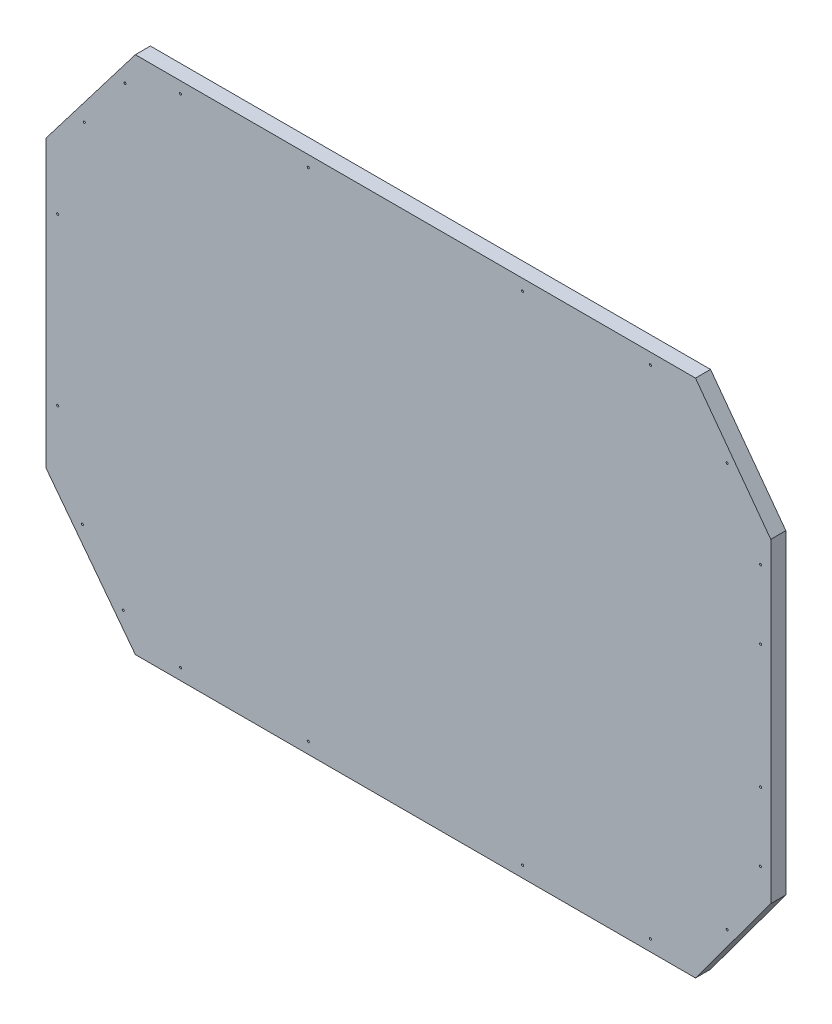
from build123d import *

# Parameters (mm, degrees)
BOSS_EXTRUDE2_DEPTH                               = 20
CSK_FOR_3_FLAT_HEAD_MACHINE_SCREW_100_D           = 2.794
CSK_FOR_3_FLAT_HEAD_MACHINE_SCREW_100_DEPTH       = 20
CSK_FOR_3_FLAT_HEAD_MACHINE_SCREW_100_CSINK_D     = 5.0546
CSK_FOR_3_FLAT_HEAD_MACHINE_SCREW_100_CSINK_ANGLE = 100


with BuildPart() as part:
    # Sketch1 → Boss-Extrude2 (new body)
    with BuildSketch(Plane.XY):
        Polygon((0, 500.68043587), (118.58, 345.487717935), (863.58, 345.487717935), (963.71, 481.146537036), (963.71, 900.804334703), (863.58, 1036.463153804), (118.58, 1036.463153804), (0, 881.27043587), align=None)
    extrude(amount=BOSS_EXTRUDE2_DEPTH)

    # CSK for #3 Flat Head Machine Screw (100)2
    with Locations(Plane(origin=(0, 0, 0), x_dir=(-1, 0, 0), z_dir=(0, 0, -1))):
        with Locations((-950.019491684, 864.74090145), (-950.019491684, 773.32689058), (-950.019491684, 608.634912319), (-950.019491684, 517.22090145), (-905.654330921, 422.269736472), (-803.58, 360.487717935), (-633.58, 360.487717935), (-348.58, 360.487717935), (-178.58, 360.487717935), (-102.481993543, 388.446303105), (-48.296375955, 460.30671534), (-15.328698966, 580.68043587), (-15.328698966, 801.27043587), (-50.699956706, 924.831760626), (-104.885574294, 996.692172861), (-178.58, 1021.463153804), (-348.58, 1021.463153804), (-633.58, 1021.463153804), (-803.58, 1021.463153804), (-905.654330921, 959.692066427)):
            CounterSinkHole(CSK_FOR_3_FLAT_HEAD_MACHINE_SCREW_100_D / 2, CSK_FOR_3_FLAT_HEAD_MACHINE_SCREW_100_CSINK_D / 2, depth=CSK_FOR_3_FLAT_HEAD_MACHINE_SCREW_100_DEPTH, counter_sink_angle=CSK_FOR_3_FLAT_HEAD_MACHINE_SCREW_100_CSINK_ANGLE)


solid = part.part
